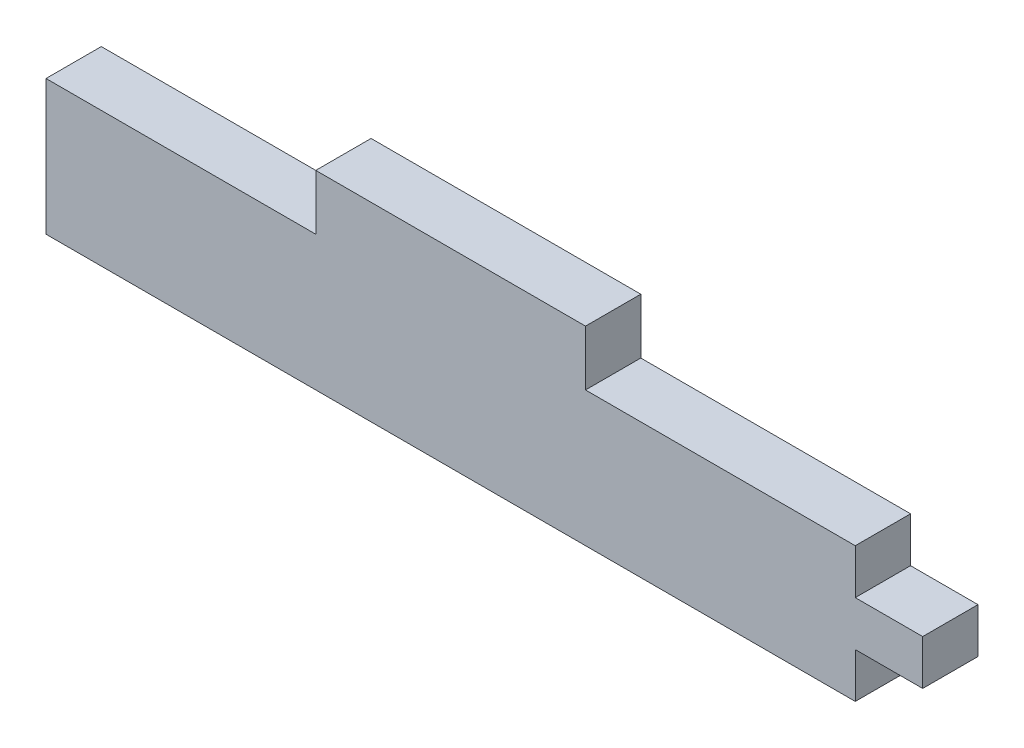
from build123d import *

# Parameters (mm, degrees)
BOSS_EXTRUDE1_DEPTH = 5.207


with BuildPart() as part:
    # Sketch1 → Boss-Extrude1 (new body)
    with BuildSketch(Plane.XY):
        Polygon((50.8, 12.7), (76.2, 12.7), (76.2, 8.466666667), (82.55, 8.466666667), (82.55, 4.233333333), (76.2, 4.233333333), (76.2, 0), (0, 0), (0, 12.7), (25.4, 12.7), (25.4, 17.907), (50.8, 17.907), align=None)
    extrude(amount=BOSS_EXTRUDE1_DEPTH)


solid = part.part
